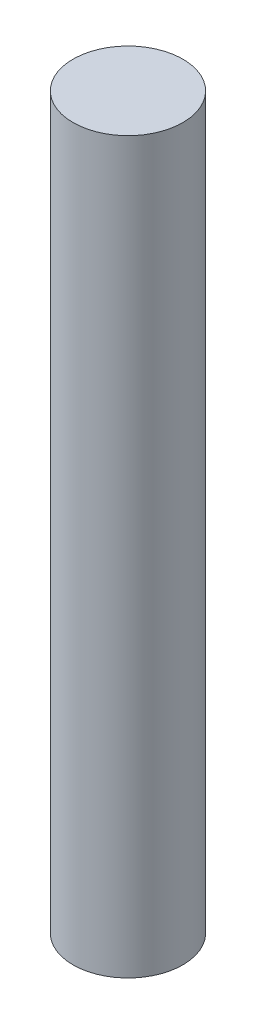
from build123d import *

# Parameters (mm, degrees)
SKETCH1_R           = 15.875
BOSS_EXTRUDE1_DEPTH = 210.82


with BuildPart() as part:
    # Sketch1 → Boss-Extrude1 (new body)
    with BuildSketch(Plane(origin=(0, 0, 0), x_dir=(1, 0, 0), z_dir=(0, 1, 0))):
        Circle(SKETCH1_R)
    extrude(amount=BOSS_EXTRUDE1_DEPTH)


solid = part.part
